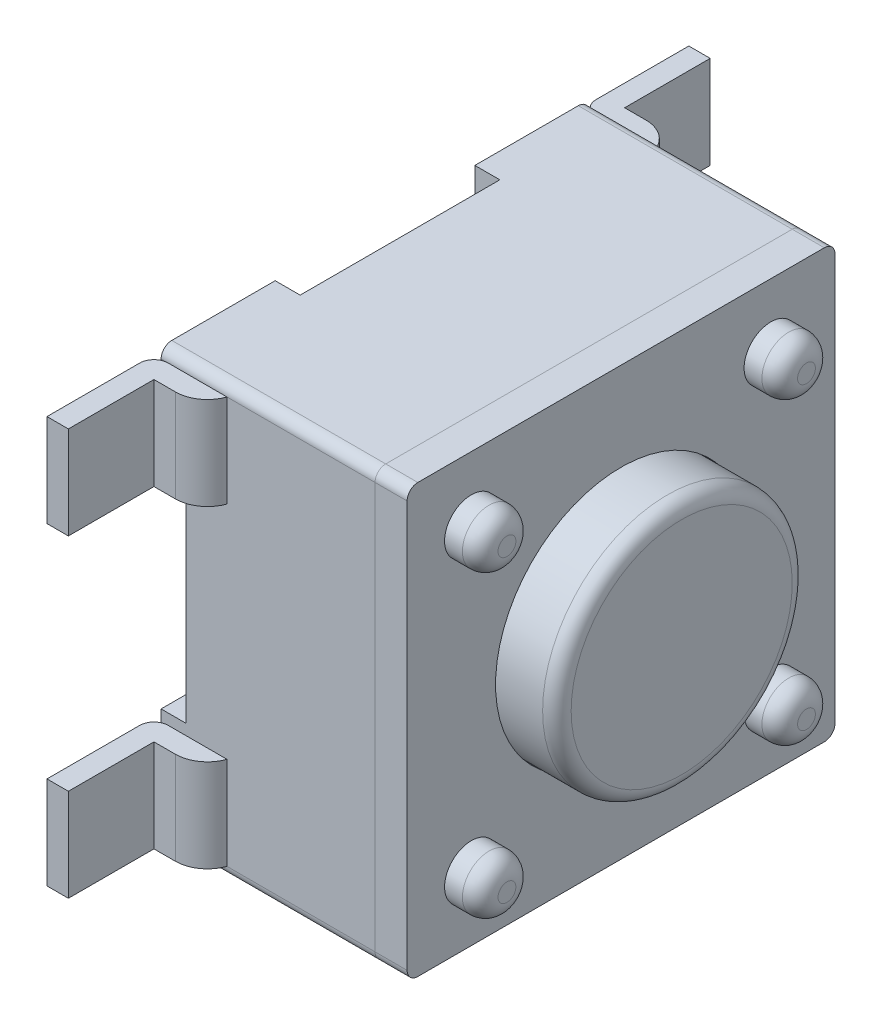
from build123d import *

# Parameters (mm, degrees)
SKETCH1_W                = 6
SKETCH1_H                = 6
BOSS_EXTRUDE1_DEPTH      = 1.5
SKETCH3_R                = 1.75
BOSS_EXTRUDE3_DEPTH      = 1.3
FILLET1_R                = 0.2
SKETCH5_W                = 6
SKETCH5_H                = 6
SKETCH5_R                = 0.375
BOSS_EXTRUDE4_DEPTH      = 0.45
SKETCH6_R                = 0.375
BOSS_EXTRUDE5_DEPTH      = 0.5
BOSS_EXTRUDE5_DEPTH_BACK = 3.45
FILLET2_R                = 0.25
FILLET3_R                = 0.15
FILLET4_R                = 0.15
BOSS_EXTRUDE6_DEPTH      = 0.65
BOSS_EXTRUDE6_2_DEPTH    = 0.65
SKETCH9_W                = 0.7
SKETCH9_H                = 2.8
CUT_EXTRUDE3_DEPTH       = 7
CIRPATTERN2_COUNT        = 4
SKETCH11_R               = 1.76
CUT_EXTRUDE5_DEPTH       = 0.45


with BuildPart() as part:
    # Sketch1 → Boss-Extrude1 (new body, symmetric)
    with BuildSketch(Plane(origin=(0, 0, 0), x_dir=(0, 0, -1), z_dir=(1, 0, 0))):
        Rectangle(SKETCH1_W, SKETCH1_H)
    extrude(amount=BOSS_EXTRUDE1_DEPTH, both=True)

    # Sketch3 → Boss-Extrude3 (add)
    with BuildSketch(Plane(origin=(1.5, 0, 0), x_dir=(0, 0, -1), z_dir=(1, 0, 0))):
        Circle(SKETCH3_R)
    extrude(amount=BOSS_EXTRUDE3_DEPTH)

    # Fillet1
    fillet1_edges = [part.edges().sort_by_distance(p)[0] for p in [
        (2.8, 0, 1.75),
    ]]
    fillet(fillet1_edges, radius=FILLET1_R)

    # Sketch6 → Boss-Extrude5 (add, two sides)
    with BuildSketch(Plane(origin=(1.95, 0, 0), x_dir=(0, 0, -1), z_dir=(1, 0, 0))) as boss_extrude5_sk:
        with Locations((-2.1, -2.1)):
            Circle(SKETCH6_R)
        with Locations((2.1, -2.1)):
            Circle(SKETCH6_R)
        with Locations((2.1, 2.1)):
            Circle(SKETCH6_R)
        with Locations((-2.1, 2.1)):
            Circle(SKETCH6_R)
    extrude(amount=BOSS_EXTRUDE5_DEPTH)
    extrude(boss_extrude5_sk.sketch, amount=-BOSS_EXTRUDE5_DEPTH_BACK)

    # Fillet2
    fillet2_edges = [part.edges().sort_by_distance(p)[0] for p in [
        (2.45, -2.1, 2.475),
        (2.45, -2.1, -1.725),
        (2.45, 2.1, -1.725),
        (2.45, 2.1, 2.475),
    ]]
    fillet(fillet2_edges, radius=FILLET2_R)

    # Fillet3
    fillet3_edges = [part.edges().sort_by_distance(p)[0] for p in [
        (0, -3, -3),
        (0, -3, 3),
        (0, 3, 3),
        (0, 3, -3),
    ]]
    fillet(fillet3_edges, radius=FILLET3_R)

    # Sketch9 → Cut-Extrude3 (cut, through all)
    with BuildSketch(Plane(origin=(0, 3, 0), x_dir=(1, 0, 0), z_dir=(0, 1, 0))):
        with Locations((-1.5, 0)):
            Rectangle(SKETCH9_W, SKETCH9_H)
    cut_extrude3 = extrude(amount=-CUT_EXTRUDE3_DEPTH, mode=Mode.SUBTRACT)

    # CirPattern2: Cut-Extrude3 ×4 about axis
    cirpattern2_axis = Axis((3.19, 0, 0), (-1, 0, 0))
    for i in range(1, CIRPATTERN2_COUNT):
        add(cut_extrude3.rotate(cirpattern2_axis, i * 360 / CIRPATTERN2_COUNT), mode=Mode.SUBTRACT)


with BuildPart() as body_2:
    # Sketch5 → Boss-Extrude4 (new body)
    with BuildSketch(Plane.ZY.offset(-1.95)):
        Rectangle(SKETCH5_W, SKETCH5_H)
        with Locations((2.1, 2.1)):
            Circle(SKETCH5_R, mode=Mode.SUBTRACT)
        with Locations((-2.1, 2.1)):
            Circle(SKETCH5_R, mode=Mode.SUBTRACT)
        with Locations((-2.1, -2.1)):
            Circle(SKETCH5_R, mode=Mode.SUBTRACT)
        with Locations((2.1, -2.1)):
            Circle(SKETCH5_R, mode=Mode.SUBTRACT)
    extrude(amount=BOSS_EXTRUDE4_DEPTH)

    # Fillet4
    fillet4_edges = [body_2.edges().sort_by_distance(p)[0] for p in [
        (1.725, -3, -3),
        (1.725, -3, 3),
        (1.725, 3, 3),
        (1.725, 3, -3),
    ]]
    fillet(fillet4_edges, radius=FILLET4_R)

    # Sketch11 → Cut-Extrude5 (cut)
    with BuildSketch(Plane(origin=(1.95, 0, 0), x_dir=(0, 0, -1), z_dir=(1, 0, 0))):
        Circle(SKETCH11_R)
    extrude(amount=-CUT_EXTRUDE5_DEPTH, mode=Mode.SUBTRACT)


with BuildPart() as body_3:
    # Sketch7 → Boss-Extrude6 (new body, symmetric)
    with BuildSketch(Plane(origin=(0, -2.2, 0), x_dir=(1, 0, 0), z_dir=(0, 1, 0))):
        with BuildLine():
            Line((-1, -3), (-1.4, -3))
            ThreePointArc((-1.4, -3), (-1.541421356, -3.058578644), (-1.6, -3.2))
            Line((-1.6, -3.2), (-1.6, -4.5))
            Line((-1.6, -4.5), (-1.3, -4.5))
            Line((-1.3, -4.5), (-1.3, -3.3))
            Line((-1.3, -3.3), (-1, -3.3))
            ThreePointArc((-1, -3.3), (-0.740192379, -3.217423461), (-0.575735931, -3))
            Line((-0.575735931, -3), (-1, -3))
        make_face()
    extrude(amount=BOSS_EXTRUDE6_DEPTH, both=True)


with BuildPart() as body_4:
    # Sketch7 → Boss-Extrude6 2 (new body, symmetric)
    with BuildSketch(Plane(origin=(0, -2.2, 0), x_dir=(1, 0, 0), z_dir=(0, 1, 0))):
        with BuildLine():
            Line((-1, 3), (-0.575735931, 3))
            ThreePointArc((-0.575735931, 3), (-0.740192379, 3.217423461), (-1, 3.3))
            Line((-1, 3.3), (-1.3, 3.3))
            Line((-1.3, 3.3), (-1.3, 4.5))
            Line((-1.3, 4.5), (-1.6, 4.5))
            Line((-1.6, 4.5), (-1.6, 3.2))
            ThreePointArc((-1.6, 3.2), (-1.541421356, 3.058578644), (-1.4, 3))
            Line((-1.4, 3), (-1, 3))
        make_face()
    extrude(amount=BOSS_EXTRUDE6_2_DEPTH, both=True)


with BuildPart() as body_5:
    # Mirror3: mirrored copy
    add(body_3.part.mirror(Plane.ZX))


with BuildPart() as body_6:
    # Mirror5: mirrored copy
    add(body_5.part.mirror(Plane.XY))


solid = Compound([part.part, body_2.part, body_3.part, body_4.part, body_5.part, body_6.part])
